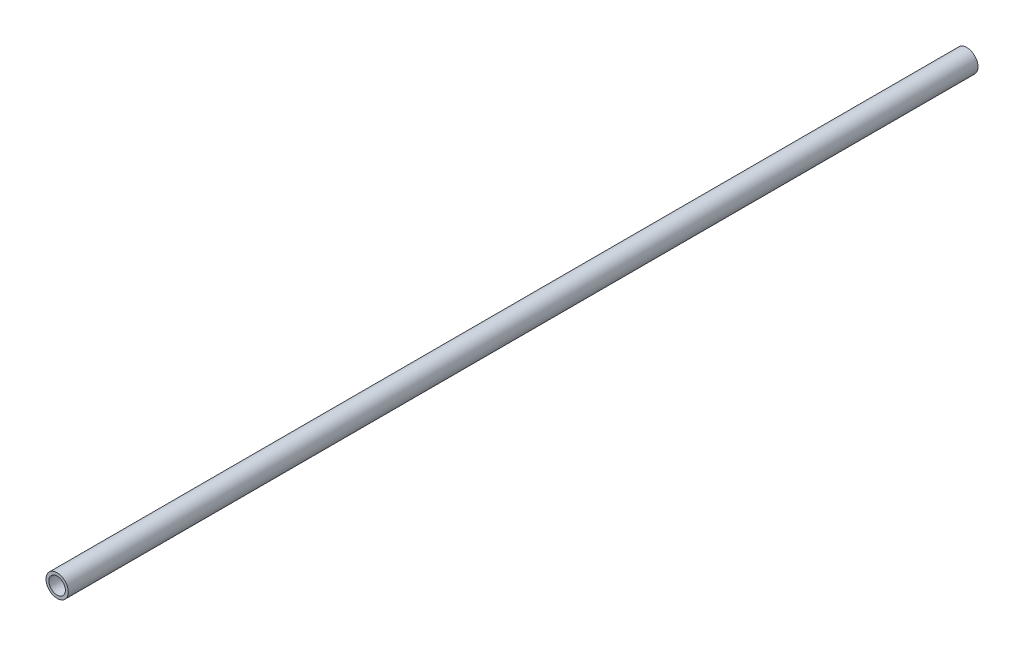
from build123d import *

# Parameters (mm, degrees)
SKETCH1_R           = 10.668
SKETCH1_R_2         = 7.8994
EXTRUDE_THIN1_DEPTH = 435


with BuildPart() as part:
    # Sketch1 → Extrude-Thin1 (new body, symmetric)
    with BuildSketch(Plane.XY):
        Circle(SKETCH1_R)
        Circle(SKETCH1_R_2, mode=Mode.SUBTRACT)
    extrude(amount=EXTRUDE_THIN1_DEPTH, both=True)


solid = part.part
